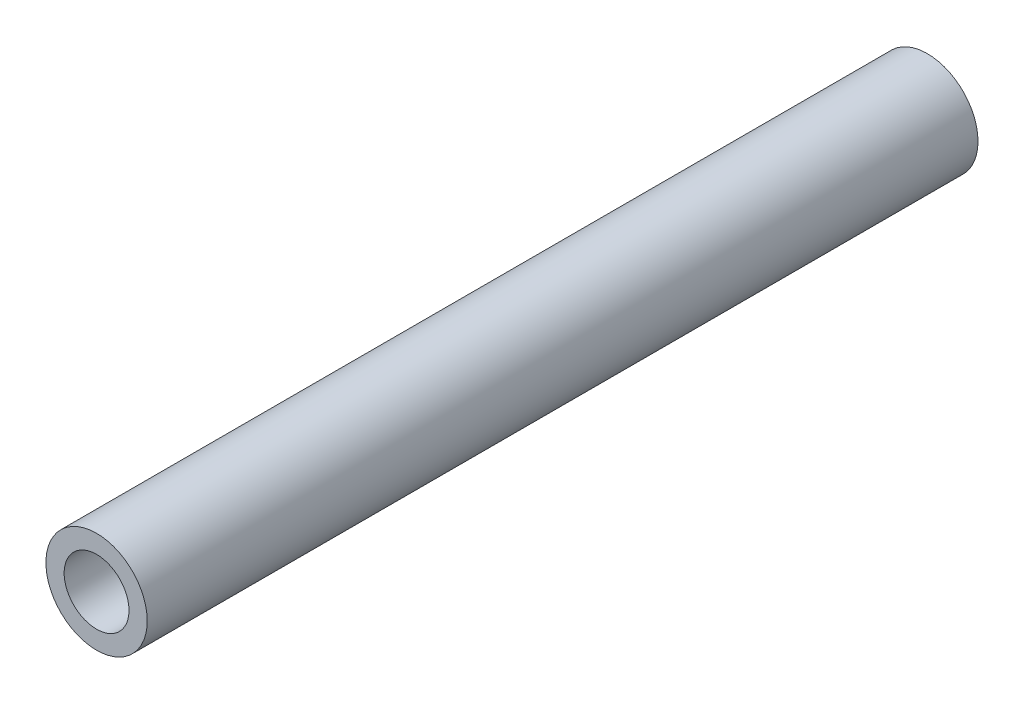
from build123d import *

# Parameters (mm, degrees)
SKETCH1_R           = 2.5
SKETCH1_R_2         = 1.6
BOSS_EXTRUDE1_DEPTH = 41


with BuildPart() as part:
    # Sketch1 → Boss-Extrude1 (new body)
    with BuildSketch(Plane.XY):
        Circle(SKETCH1_R)
        Circle(SKETCH1_R_2, mode=Mode.SUBTRACT)
    extrude(amount=BOSS_EXTRUDE1_DEPTH)


solid = part.part
